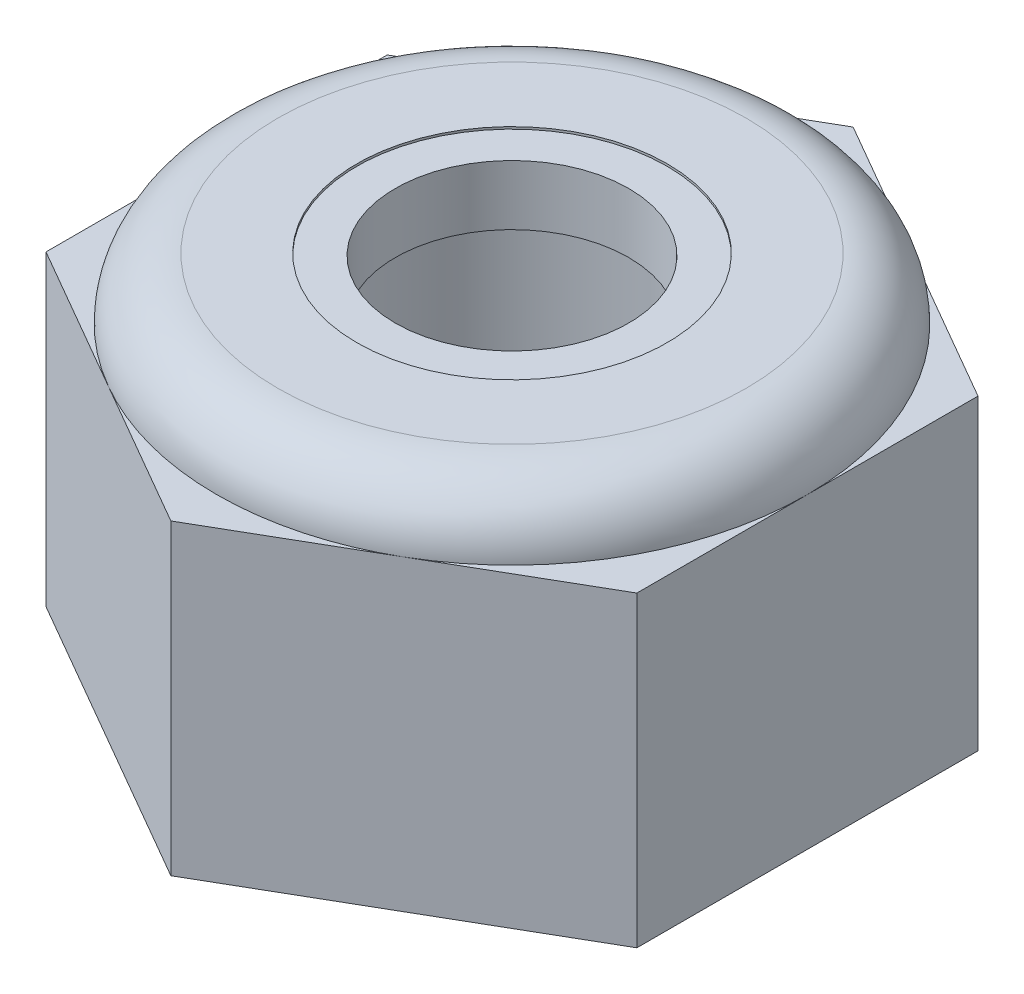
from build123d import *

# Parameters (mm, degrees)
BOSS_EXTRUDE1_DEPTH         = 4.159999906
TAP_DRILL_FOR_M5X0_8_TAP1_D = 4.2
SKETCH8_W                   = 0.52
SKETCH8_H                   = 0.81


with BuildPart() as part:
    # Sketch1 → Boss-Extrude1 (new body)
    with BuildSketch(Plane(origin=(0, 0, 0), x_dir=(1, 0, 0), z_dir=(0, 1, 0))):
        Polygon((-4, -2.309401077), (0, -4.618802154), (4, -2.309401077), (4, 2.309401077), (0, 4.618802154), (-4, 2.309401077), align=None)
    extrude(amount=BOSS_EXTRUDE1_DEPTH)

    # Sketch3 → Revolve1 (revolve)
    with BuildSketch(Plane.XY):
        with BuildLine():
            Line((3.17, 4.989999906), (0, 4.989999906))
            Line((0, 4.989999906), (0, 4.159999906))
            Line((0, 4.159999906), (4, 4.159999906))
            ThreePointArc((4, 4.159999906), (3.756898628, 4.746898534), (3.17, 4.989999906))
        make_face()
    revolve(axis=Axis((0, 4.989999906, 0), (0, -1, 0)))

    # Tap Drill for M5x0.8 Tap1 (through all)
    with Locations(Plane(origin=(0, 0, 0), x_dir=(-1, 0, 0), z_dir=(0, -1, 0))):
        with Locations((0, 0)):
            Hole(TAP_DRILL_FOR_M5X0_8_TAP1_D / 2)

    # Sketch8 → Revolve2 (revolve)
    with BuildSketch(Plane.XY):
        with Locations((1.84, 4.554999966)):
            Rectangle(SKETCH8_W, SKETCH8_H)
    revolve(axis=Axis((0, 4.989999906, 0), (0, -1, 0)))


solid = part.part
